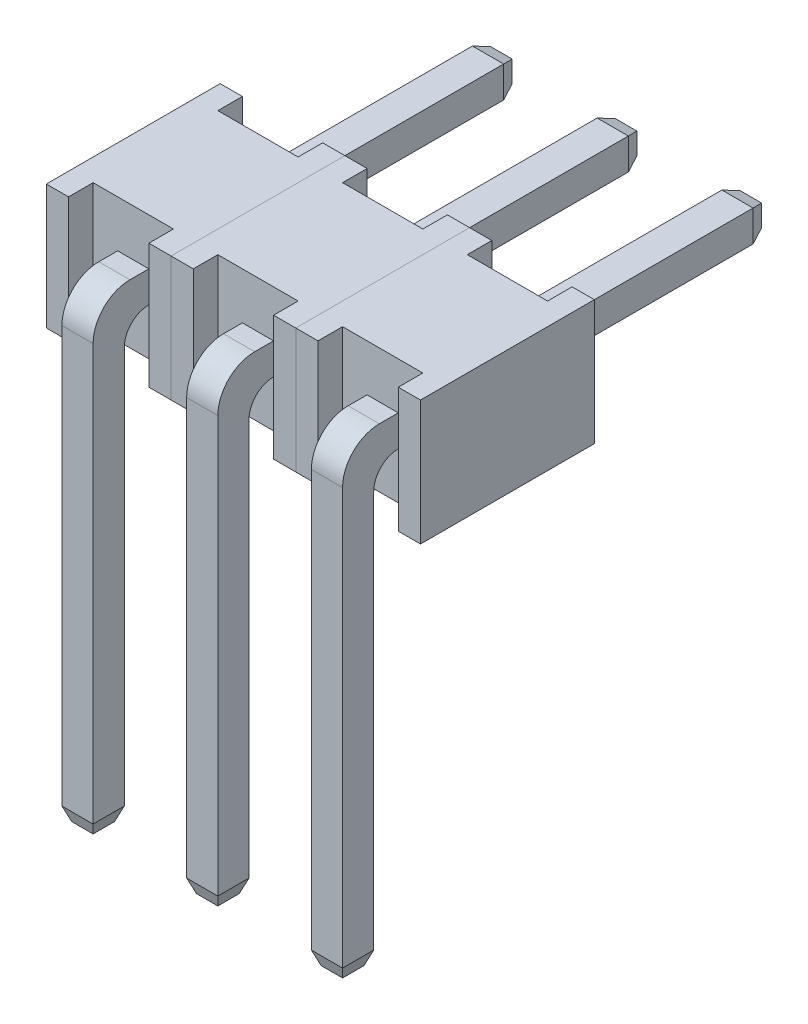
from build123d import *

# Parameters (mm, degrees)
SKETCH2_W             = 0.635
SKETCH2_H             = 9.5
BOSS_EXTRUDE1_DEPTH   = 0.635
SKETCH3_W             = 0.635
SKETCH3_H             = 0.635
BOSS_EXTRUDE2_DEPTH   = 8
FILLET1_R             = 0.5
FILLET2_R             = 0.75
SKETCH4_W             = 0.4525
SKETCH4_H             = 2.54
BOSS_EXTRUDE3_DEPTH   = 0.5
BOSS_EXTRUDE3_2_DEPTH = 0.5
SKETCH5_W             = 2.54
SKETCH5_H             = 2.54
BOSS_EXTRUDE4_DEPTH   = 2.54
SKETCH6_W             = 0.4525
SKETCH6_H             = 2.54
BOSS_EXTRUDE5_DEPTH   = 0.5
CHAMFER1_SIZE         = 0.1
CHAMFER1_SIZE2        = 0.274747742
CHAMFER2_SIZE         = 0.1
CHAMFER2_SIZE2        = 0.274747742
NUM_PINS_COUNT        = 3
NUM_PINS_PITCH        = 2.54


with BuildPart() as part:
    # Sketch2 → Boss-Extrude1 (new body)
    with BuildSketch(Plane.XY):
        with Locations((1.27, 4.75)):
            Rectangle(SKETCH2_W, SKETCH2_H)
    extrude(amount=-BOSS_EXTRUDE1_DEPTH)

    # Sketch3 → Boss-Extrude2 (add)
    with BuildSketch(Plane(origin=(0, 0, -0.635), x_dir=(-1, 0, 0), z_dir=(0, 0, -1))):
        with Locations((-1.27, 9.1825)):
            Rectangle(SKETCH3_W, SKETCH3_H)
    extrude(amount=BOSS_EXTRUDE2_DEPTH)

    # Fillet1
    fillet1_edges = [part.edges().sort_by_distance(p)[0] for p in [
        (1.27, 8.865, -0.635),
    ]]
    fillet(fillet1_edges, radius=FILLET1_R)

    # Fillet2
    fillet2_edges = [part.edges().sort_by_distance(p)[0] for p in [
        (1.27, 9.5, 0),
    ]]
    fillet(fillet2_edges, radius=FILLET2_R)



with BuildPart() as body_2:
    # Sketch4 → Boss-Extrude3 (new body)
    with BuildSketch(Plane(origin=(0, 0, -0.635), x_dir=(-1, 0, 0), z_dir=(0, 0, -1))):
        with Locations((-0.22625, 9.1825)):
            Rectangle(SKETCH4_W, SKETCH4_H)
    extrude(amount=BOSS_EXTRUDE3_DEPTH)


with BuildPart() as body_3:
    # Sketch4 → Boss-Extrude3 2 (new body)
    with BuildSketch(Plane(origin=(0, 0, -0.635), x_dir=(-1, 0, 0), z_dir=(0, 0, -1))):
        with Locations((-2.31375, 9.1825)):
            Rectangle(SKETCH4_W, SKETCH4_H)
    extrude(amount=BOSS_EXTRUDE3_2_DEPTH)


with BuildPart() as part_1:
    add(part.part)

    add(body_2.part)  # Boss-Extrude4 merges body 2

    add(body_3.part)  # Boss-Extrude4 merges body 3
    # Sketch5 → Boss-Extrude4 (add)
    with BuildSketch(Plane(origin=(0, 0, -1.135), x_dir=(-1, 0, 0), z_dir=(0, 0, -1))):
        with Locations((-1.27, 9.1825)):
            Rectangle(SKETCH5_W, SKETCH5_H)
    extrude(amount=BOSS_EXTRUDE4_DEPTH)

    # Sketch6 → Boss-Extrude5 (add)
    with BuildSketch(Plane(origin=(0, 0, -3.675), x_dir=(-1, 0, 0), z_dir=(0, 0, -1))):
        with Locations((-0.22625, 9.1825)):
            Rectangle(SKETCH6_W, SKETCH6_H)
        with Locations((-2.31375, 9.1825)):
            Rectangle(SKETCH6_W, SKETCH6_H)
    extrude(amount=BOSS_EXTRUDE5_DEPTH)

    # Chamfer1
    chamfer1_edges = [part_1.edges().sort_by_distance(p)[0] for p in [
        (0.9525, 9.1825, -8.635),
        (1.27, 9.5, -8.635),
        (1.5875, 9.1825, -8.635),
        (1.27, 8.865, -8.635),
    ]]
    chamfer1_side = [part_1.faces().sort_by_distance(p)[0] for p in [
        (1.27, 9.1825, -8.635),
    ]]
    chamfer(chamfer1_edges, length=CHAMFER1_SIZE, length2=CHAMFER1_SIZE2, reference=chamfer1_side[0])

    # Chamfer2
    chamfer2_edges = [part_1.edges().sort_by_distance(p)[0] for p in [
        (1.27, 0, 0),
        (1.5875, 0, -0.3175),
        (0.9525, 0, -0.3175),
        (1.27, 0, -0.635),
    ]]
    chamfer2_side = [part_1.faces().sort_by_distance(p)[0] for p in [
        (1.27, 0, -0.3175),
    ]]
    chamfer(chamfer2_edges, length=CHAMFER2_SIZE, length2=CHAMFER2_SIZE2, reference=chamfer2_side[0])


with BuildPart() as num_pins_1:
    # Num pins: pattern copy
    add(part_1.part.moved(Location(Vector(1, 0, 0) * (1 * NUM_PINS_PITCH))))


with BuildPart() as num_pins_2:
    # Num pins: pattern copy
    add(part_1.part.moved(Location(Vector(1, 0, 0) * (2 * NUM_PINS_PITCH))))


solid = Compound([part_1.part, num_pins_1.part, num_pins_2.part])
